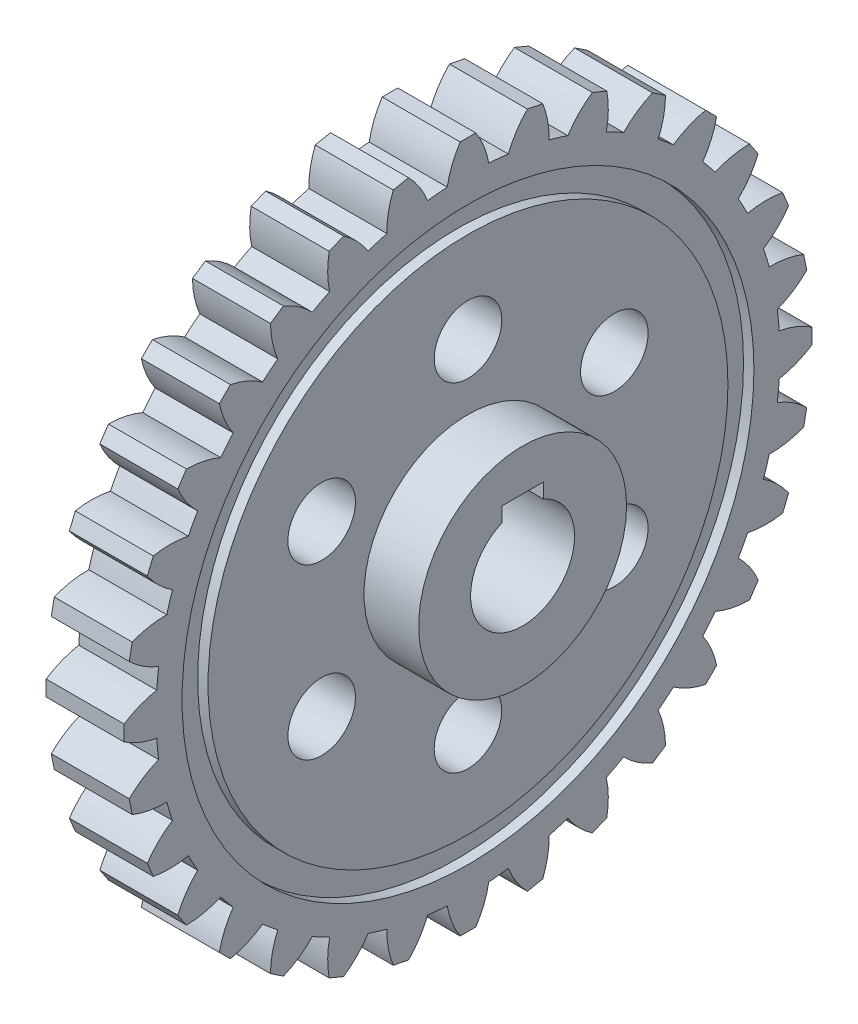
from build123d import *

# Parameters (mm, degrees)
SKETCH1_R           = 60
BOSS_EXTRUDE1_DEPTH = 7.5
BOSS_EXTRUDE2_DEPTH = 15
CIRPATTERN1_COUNT   = 32
SKETCH3_R           = 20
BOSS_EXTRUDE3_DEPTH = 18
CUT_EXTRUDE1_DEPTH  = 37
SKETCH5_R           = 55
SKETCH5_R_2         = 50
CUT_EXTRUDE3_DEPTH  = 2
SKETCH6_R           = 6.5
CUT_EXTRUDE4_DEPTH  = 26.5
CIRPATTERN2_COUNT   = 6


with BuildPart() as part:
    # Sketch1 → Boss-Extrude1 (new body, symmetric)
    with BuildSketch(Plane(origin=(0, 0, 0), x_dir=(0, 0, -1), z_dir=(1, 0, 0))):
        Circle(SKETCH1_R)
    extrude(amount=BOSS_EXTRUDE1_DEPTH, both=True)

    # Sketch2 → Boss-Extrude2 (add, through all)
    with BuildSketch(Plane(origin=(7.5, 0, 0), x_dir=(0, 0, -1), z_dir=(1, 0, 0))):
        with BuildLine():
            Line((-1.5, 66.136518188), (1.5, 66.136518188))
            ThreePointArc((1.5, 66.136518188), (3.064324573, 63.126846965), (4, 59.866518188))
            ThreePointArc((4, 59.866518188), (0, 60), (-4, 59.866518188))
            ThreePointArc((-4, 59.866518188), (-3.064324573, 63.126846965), (-1.5, 66.136518188))
        make_face()
    boss_extrude2 = extrude(amount=-BOSS_EXTRUDE2_DEPTH)

    # CirPattern1: Boss-Extrude2 ×32 about axis
    cirpattern1_axis = Axis((0, 0, 0), (1, 0, 0))
    for i in range(1, CIRPATTERN1_COUNT):
        add(boss_extrude2.rotate(cirpattern1_axis, i * 360 / CIRPATTERN1_COUNT))

    # Sketch3 → Boss-Extrude3 (add, symmetric)
    with BuildSketch(Plane(origin=(0, 0, 0), x_dir=(0, 0, -1), z_dir=(1, 0, 0))):
        Circle(SKETCH3_R)
    extrude(amount=BOSS_EXTRUDE3_DEPTH, both=True)

    # Sketch4 → Cut-Extrude1 (cut, through all)
    with BuildSketch(Plane(origin=(18, 0, 0), x_dir=(0, 0, -1), z_dir=(1, 0, 0))):
        with BuildLine():
            Line((4, 12), (-4, 12))
            Line((-4, 12), (-4, 9.16515139))
            ThreePointArc((-4, 9.16515139), (0, -10), (4, 9.16515139))
            Line((4, 9.16515139), (4, 12))
        make_face()
    extrude(amount=-CUT_EXTRUDE1_DEPTH, mode=Mode.SUBTRACT)

    # Sketch5 → Cut-Extrude3 (cut)
    with BuildSketch(Plane(origin=(7.5, 0, 0), x_dir=(0, 0, -1), z_dir=(1, 0, 0))):
        Circle(SKETCH5_R)
        Circle(SKETCH5_R_2, mode=Mode.SUBTRACT)
    cut_extrude3 = extrude(amount=-CUT_EXTRUDE3_DEPTH, mode=Mode.SUBTRACT)

    # Sketch6 → Cut-Extrude4 (cut, through all)
    with BuildSketch(Plane(origin=(7.5, 0, 0), x_dir=(0, 0, -1), z_dir=(1, 0, 0))):
        with Locations((0, 32.5)):
            Circle(SKETCH6_R)
    cut_extrude4 = extrude(amount=-CUT_EXTRUDE4_DEPTH, mode=Mode.SUBTRACT)

    # CirPattern2: Cut-Extrude4 ×6 about axis
    cirpattern2_axis = Axis((0, 0, 0), (1, 0, 0))
    for i in range(1, CIRPATTERN2_COUNT):
        add(cut_extrude4.rotate(cirpattern2_axis, i * 360 / CIRPATTERN2_COUNT), mode=Mode.SUBTRACT)

    # Mirror1: Cut-Extrude3 across plane
    add(cut_extrude3.mirror(Plane(origin=(0, 0, 0), x_dir=(0, 0, 1), z_dir=(1, 0, 0))), mode=Mode.SUBTRACT)


solid = part.part
